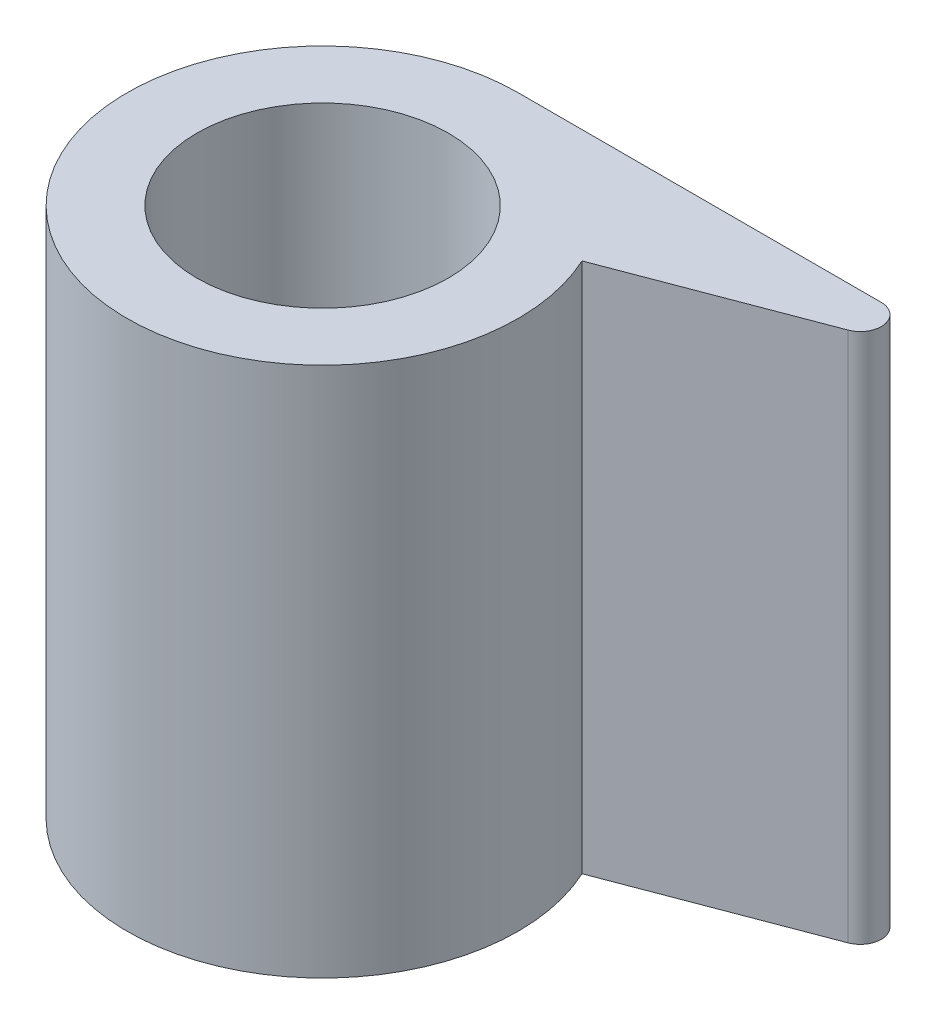
from build123d import *

# Parameters (mm, degrees)
SALIENTE_EXTRUIR1_DEPTH = 19
CROQUIS3_R              = 4.5
CORTAR_EXTRUIR1_DEPTH   = 19


with BuildPart() as part:
    # Croquis2 → Saliente-Extruir1 (new body)
    with BuildSketch(Plane(origin=(0, 0, 0), x_dir=(1, 0, 0), z_dir=(0, 1, 0))):
        with BuildLine():
            Line((-13.873049235, 8.116898032), (-0.873049235, 8.116898032))
            ThreePointArc((-0.873049235, 8.116898032), (-0.135335411, 7.502095351), (-0.607084084, 6.665640205))
            Line((-0.607084084, 6.665640205), (-7.515172482, 4.045618436))
            ThreePointArc((-7.515172482, 4.045618436), (-17.647897389, -4.778059255), (-13.873049235, 8.116898032))
        make_face()
    extrude(amount=SALIENTE_EXTRUIR1_DEPTH)

    # Croquis3 → Cortar-Extruir1 (cut)
    with BuildSketch(Plane(origin=(0, 19, 0), x_dir=(1, 0, 0), z_dir=(0, 1, 0))):
        with Locations((-13.873049235, 1.116898032)):
            Circle(CROQUIS3_R)
    extrude(amount=-CORTAR_EXTRUIR1_DEPTH, mode=Mode.SUBTRACT)


solid = part.part
